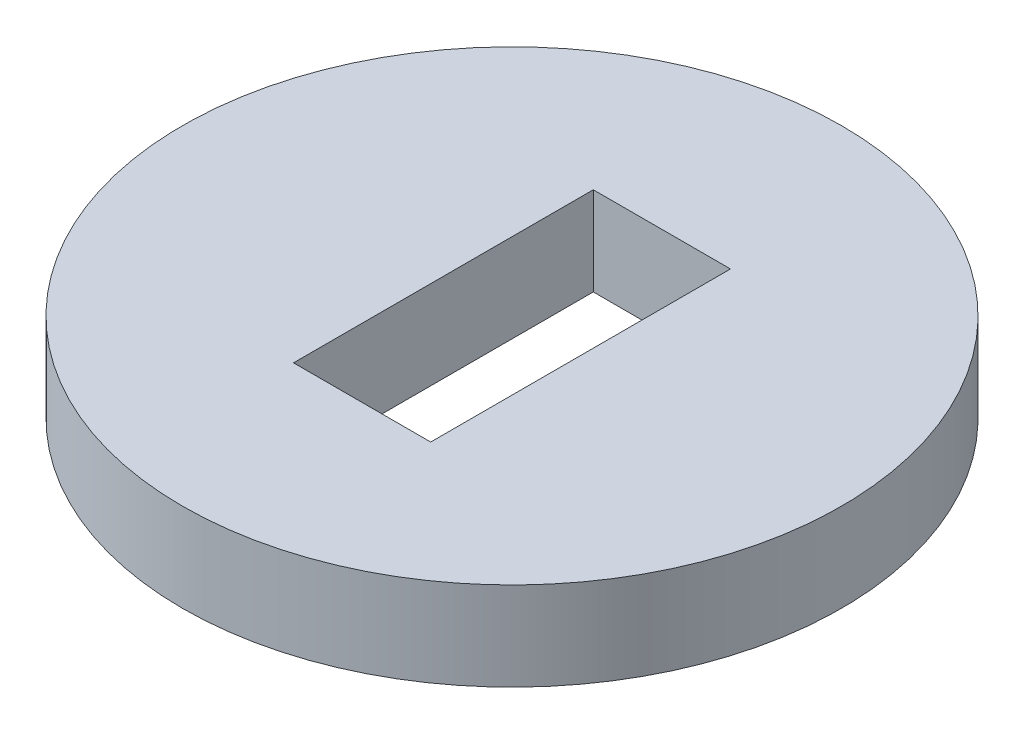
from build123d import *

# Parameters (mm, degrees)
SKETCH1_R           = 6.59
SKETCH1_W           = 2.7432
SKETCH1_H           = 5.9944
BOSS_EXTRUDE1_DEPTH = 1.77


with BuildPart() as part:
    # Sketch1 → Boss-Extrude1 (new body)
    with BuildSketch(Plane(origin=(0, 0, 0), x_dir=(1, 0, 0), z_dir=(0, 1, 0))):
        Circle(SKETCH1_R)
        Rectangle(SKETCH1_W, SKETCH1_H, mode=Mode.SUBTRACT)
    extrude(amount=BOSS_EXTRUDE1_DEPTH)


solid = part.part
